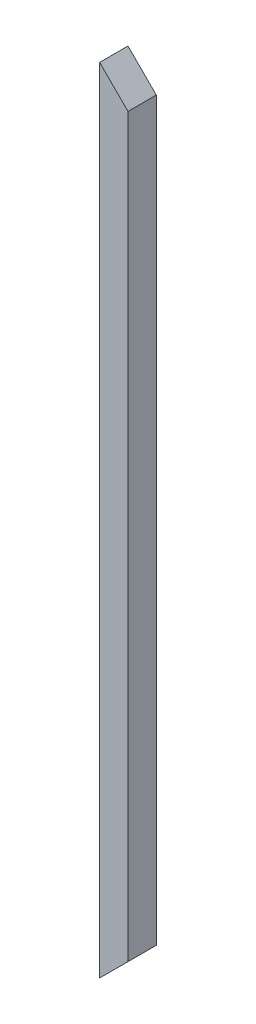
from build123d import *

# Parameters (mm, degrees)
SKETCH1_W           = 15
SKETCH1_H           = 15
BOSS_EXTRUDE1_DEPTH = 420
CUT_EXTRUDE1_DEPTH  = 30


with BuildPart() as part:
    # Sketch1 → Boss-Extrude1 (new body)
    with BuildSketch(Plane(origin=(0, 0, 0), x_dir=(1, 0, 0), z_dir=(0, 1, 0))):
        Rectangle(SKETCH1_W, SKETCH1_H)
    extrude(amount=BOSS_EXTRUDE1_DEPTH)

    # Sketch2 → Cut-Extrude1 (cut)
    with BuildSketch(Plane.XY.offset(7.5)):
        Polygon((-7.5, 420), (7.5, 405), (7.5, 420), align=None)
        Polygon((-7.5, 0), (7.5, 15), (7.5, 0), align=None)
    extrude(amount=-CUT_EXTRUDE1_DEPTH, mode=Mode.SUBTRACT)


solid = part.part
